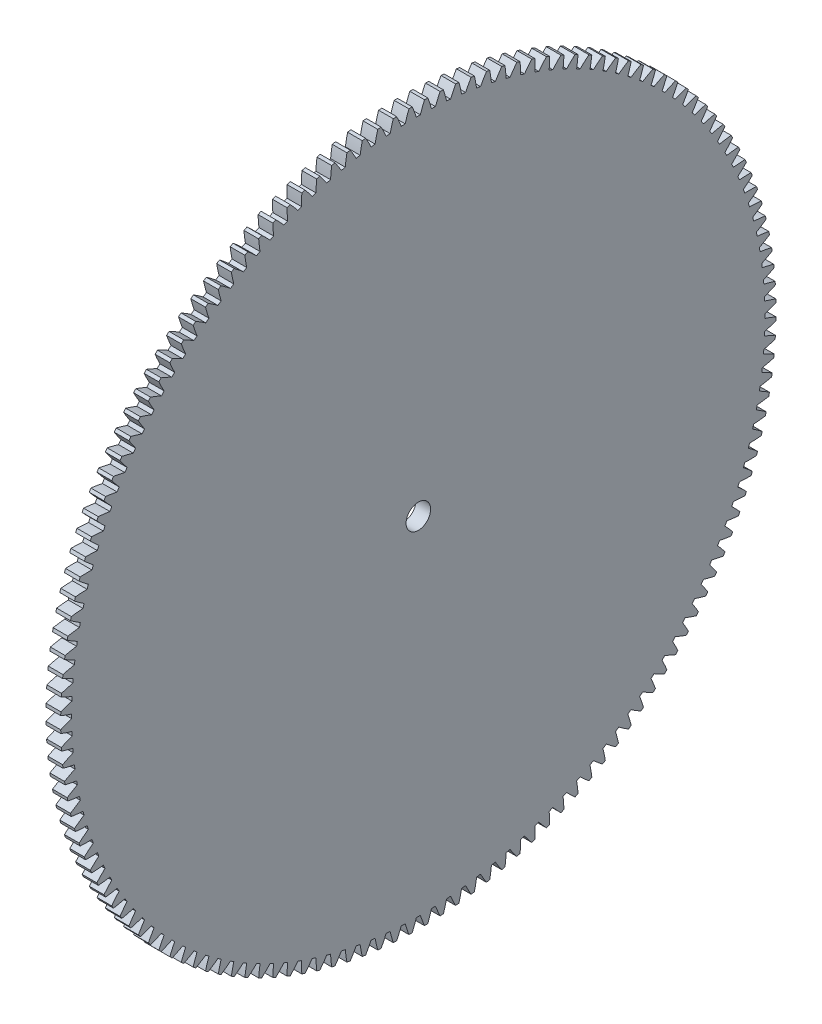
from build123d import *

# Parameters (mm, degrees)
BASPROSKE_W     = 3
BASPROSKE_H     = 73
TOOTHCUT_DEPTH  = 104.281169629
TEETHCUTS_COUNT = 144
TEETHCUTS_ANGLE = 357.5
BORSKE_R        = 2.5
BORE_DEPTH      = 50.0000508


with BuildPart() as part:
    # BasProSke → Base-Revolve (revolve)
    with BuildSketch(Plane(origin=(0, 0, 0), x_dir=(1, 0, 0), z_dir=(0, 1, 0)), mode=Mode.PRIVATE) as base_revolve_sk:
        with Locations((1.5, 36.5)):
            Rectangle(BASPROSKE_W, BASPROSKE_H)
    revolve(base_revolve_sk.sketch.rotate(Axis((-10, 0, 0), (1, 0, 0)), 180), axis=Axis((-10, 0, 0), (1, 0, 0)))

    # TooCutSke → ToothCut (cut, through all)
    with BuildSketch(Plane(origin=(0, 0, 0), x_dir=(0, 0, -1), z_dir=(1, 0, 0))):
        with BuildLine():
            ThreePointArc((0.407374934, 70.747827152), (0, 70.749), (-0.407374934, 70.747827152))
            ThreePointArc((-0.407374934, 70.747827152), (-0.812023436, 71.890157733), (-1.264371473, 73.014453432))
            ThreePointArc((-1.264371473, 73.014453432), (0, 73.0254), (1.264371473, 73.014453432))
            ThreePointArc((1.264371473, 73.014453432), (0.812023436, 71.890157733), (0.407374934, 70.747827152))
        make_face()
    toothcut = extrude(amount=TOOTHCUT_DEPTH, mode=Mode.SUBTRACT)

    # TeethCuts: ToothCut ×144 about axis
    teethcuts_axis = Axis((-10, 0, 0), (1, 0, 0))
    for i in range(1, TEETHCUTS_COUNT):
        add(toothcut.rotate(teethcuts_axis, i * TEETHCUTS_ANGLE / (TEETHCUTS_COUNT - 1)), mode=Mode.SUBTRACT)

    # BorSke → Bore (cut, symmetric)
    with BuildSketch(Plane(origin=(0, 0, 0), x_dir=(0, 0, -1), z_dir=(1, 0, 0))):
        with Locations(Location((0, 0, 0), (0, 0, 180))):
            Circle(BORSKE_R)
    extrude(amount=BORE_DEPTH, both=True, mode=Mode.SUBTRACT)


solid = part.part
